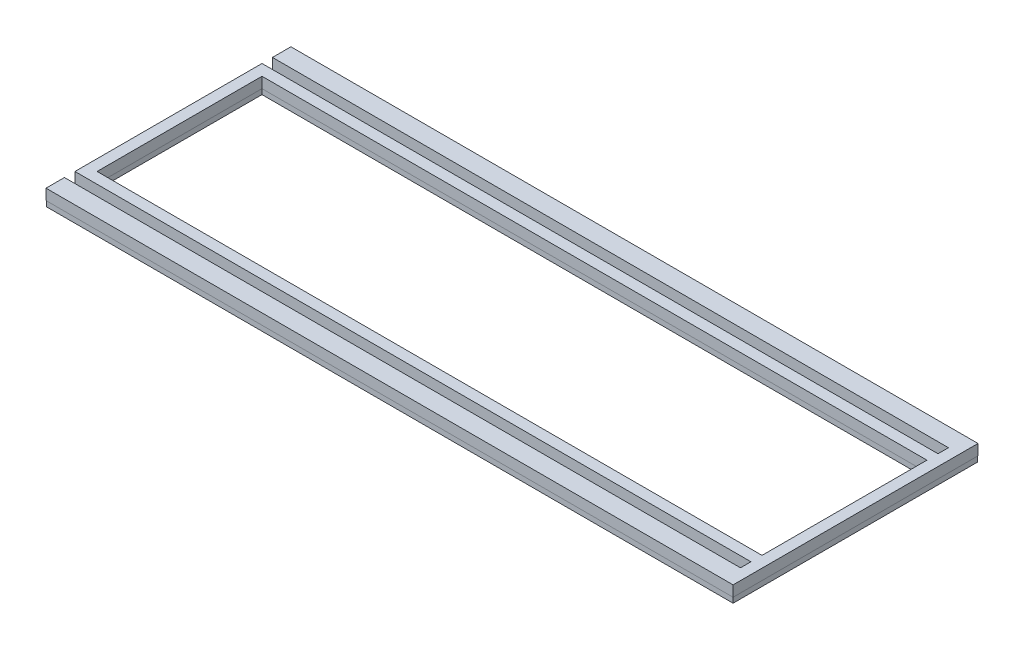
from build123d import *

# Parameters (mm, degrees)
SKETCH1_W           = 393.7
SKETCH1_H           = 97.79635
BOSS_EXTRUDE1_DEPTH = 1.5875
SKETCH4_W           = 393.4968
SKETCH4_H           = 97.59315
BOSS_EXTRUDE4_DEPTH = 6.35


with BuildPart() as part:
    # Sketch1 → Boss-Extrude1 (new body, symmetric)
    with BuildSketch(Plane(origin=(0, 0, 0), x_dir=(1, 0, 0), z_dir=(0, 1, 0))):
        Polygon((196.85, 55.248175), (-203.2, 55.248175), (-203.2, -55.248175), (196.85, -55.248175), (196.85, -61.648975), (-203.2, -61.648975), (-203.2, -72.3646), (190.5, -72.3646), (203.2, -72.3646), (203.2, 72.3646), (190.5, 72.3646), (-203.2, 72.3646), (-203.2, 61.648975), (196.85, 61.648975), align=None)
        Rectangle(SKETCH1_W, SKETCH1_H, mode=Mode.SUBTRACT)
    extrude(amount=BOSS_EXTRUDE1_DEPTH, both=True)

    # Sketch4 → Boss-Extrude4 (add)
    with BuildSketch(Plane(origin=(0, 1.5875, 0), x_dir=(1, 0, 0), z_dir=(0, 1, 0))):
        Polygon((-203.3016, 61.547375), (196.7484, 61.547375), (196.7484, 55.349775), (-203.3016, 55.349775), (-203.3016, -55.349775), (196.7484, -55.349775), (196.7484, -61.547375), (-203.3016, -61.547375), (-203.3016, -72.4662), (203.3016, -72.4662), (203.3016, 72.4662), (-203.3016, 72.4662), align=None)
        Rectangle(SKETCH4_W, SKETCH4_H, mode=Mode.SUBTRACT)
    extrude(amount=BOSS_EXTRUDE4_DEPTH)


solid = part.part
